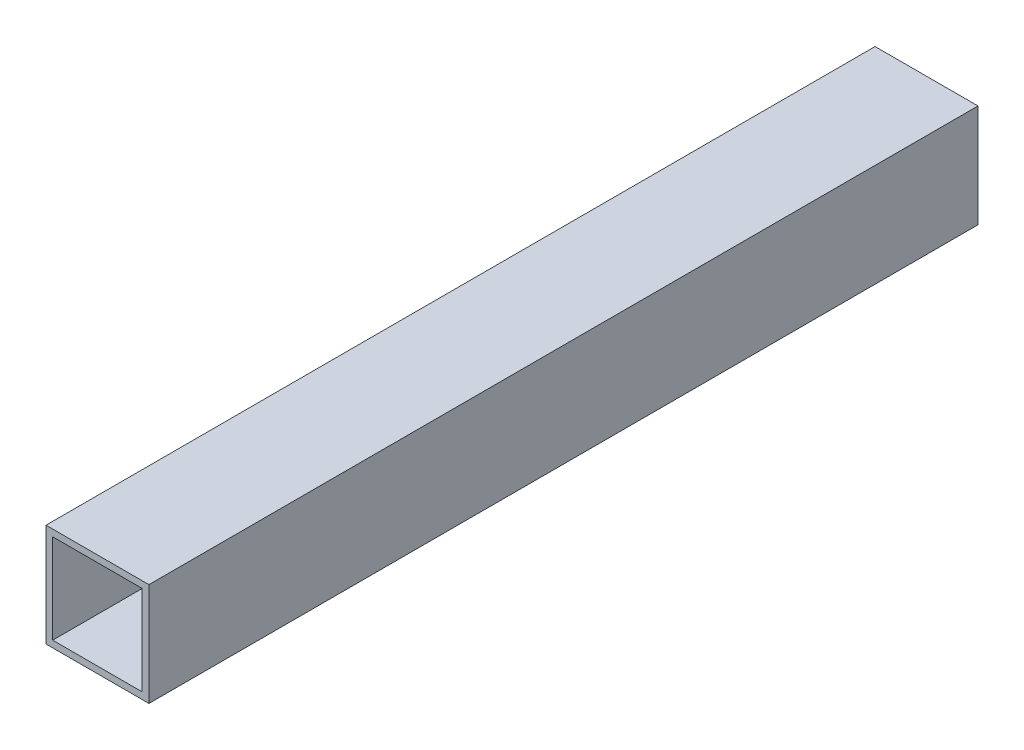
from build123d import *

# Parameters (mm, degrees)
SKETCH1_W           = 25.4
SKETCH1_H           = 25.4
SKETCH1_W_2         = 22.098
SKETCH1_H_2         = 22.098
BOSS_EXTRUDE1_DEPTH = 204.6


with BuildPart() as part:
    # Sketch1 → Boss-Extrude1 (new body)
    with BuildSketch(Plane.XY):
        Rectangle(SKETCH1_W, SKETCH1_H)
        Rectangle(SKETCH1_W_2, SKETCH1_H_2, mode=Mode.SUBTRACT)
    extrude(amount=BOSS_EXTRUDE1_DEPTH)


solid = part.part
